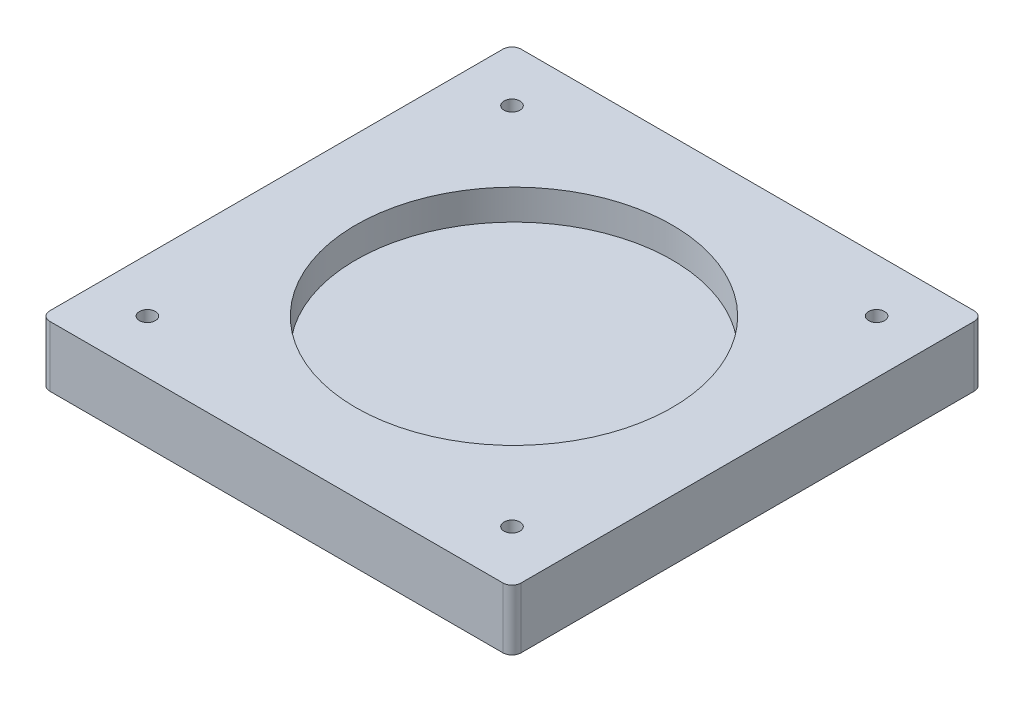
from build123d import *

# Parameters (mm, degrees)
SKETCH1_R           = 2.637642313
SKETCH1_R_2         = 73
BOSS_EXTRUDE1_DEPTH = 20
SKETCH4_R           = 73
SKETCH4_R_2         = 52.25
BOSS_EXTRUDE2_DEPTH = 10
SKETCH5_R           = 73
BOSS_EXTRUDE3_DEPTH = 10


with BuildPart() as part:
    # Sketch1 → Boss-Extrude1 (new body)
    with BuildSketch(Plane(origin=(0, 0, 0), x_dir=(1, 0, 0), z_dir=(0, 1, 0))):
        with BuildLine():
            Line((77.460838348, -75.098177713), (77.460838348, 74.577424045))
            ThreePointArc((77.460838348, 74.577424045), (76.578174547, 76.708362964), (74.447235628, 77.591026765))
            Line((74.447235628, 77.591026765), (-75.22836613, 77.591026765))
            ThreePointArc((-75.22836613, 77.591026765), (-77.359305049, 76.708362964), (-78.24196885, 74.577424045))
            Line((-78.24196885, 74.577424045), (-78.24196885, -75.098177713))
            ThreePointArc((-78.24196885, -75.098177713), (-77.359305049, -77.229116632), (-75.22836613, -78.111780433))
            Line((-75.22836613, -78.111780433), (74.447235628, -78.111780433))
            ThreePointArc((74.447235628, -78.111780433), (76.578174547, -77.229116632), (77.460838348, -75.098177713))
        make_face()
        with Locations((-60.604326536, -60.47413812)):
            Circle(SKETCH1_R, mode=Mode.SUBTRACT)
        with Locations((-60.604326536, 59.953384452)):
            Circle(SKETCH1_R, mode=Mode.SUBTRACT)
        with Locations((59.823196035, 59.953384452)):
            Circle(SKETCH1_R, mode=Mode.SUBTRACT)
        with Locations((59.823196035, -60.47413812)):
            Circle(SKETCH1_R, mode=Mode.SUBTRACT)
        Circle(SKETCH1_R_2, mode=Mode.SUBTRACT)
    extrude(amount=BOSS_EXTRUDE1_DEPTH)

    # Sketch4 → Boss-Extrude2 (add)
    with BuildSketch(Plane(origin=(0, 20, 0), x_dir=(1, 0, 0), z_dir=(0, 1, 0))):
        Circle(SKETCH4_R)
        Circle(SKETCH4_R_2, mode=Mode.SUBTRACT)
    extrude(amount=-BOSS_EXTRUDE2_DEPTH)

    # Sketch5 → Boss-Extrude3 (add)
    with BuildSketch(Plane.XZ.offset(-10)):
        Circle(SKETCH5_R)
    extrude(amount=BOSS_EXTRUDE3_DEPTH)


solid = part.part
